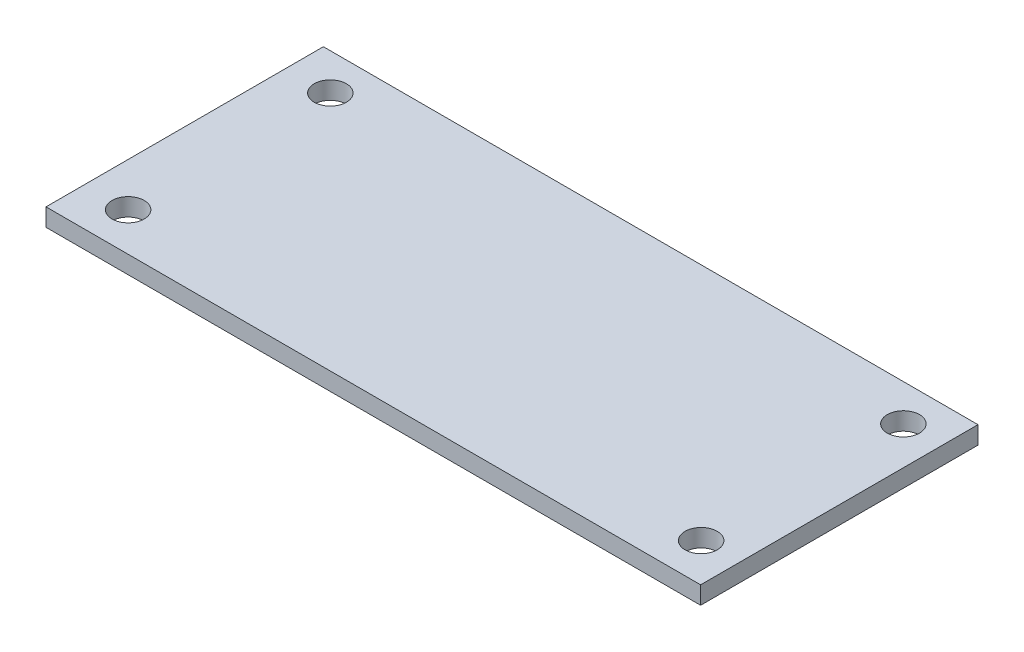
from build123d import *

# Parameters (mm, degrees)
SKETCH1_W                 = 59.944
SKETCH1_H                 = 25.4
BOSS_EXTRUDE1_DEPTH       = 1.6256
F_4_CLEARANCE_HOLE1_D     = 2.9464
F_4_CLEARANCE_HOLE1_DEPTH = 56.388
F_4_CLEARANCE_HOLE1_TIP   = 0.885187864


with BuildPart() as part:
    # Sketch1 → Boss-Extrude1 (new body)
    with BuildSketch(Plane(origin=(0, 0, 0), x_dir=(1, 0, 0), z_dir=(0, 1, 0))):
        Rectangle(SKETCH1_W, SKETCH1_H)
    extrude(amount=BOSS_EXTRUDE1_DEPTH)

    # #4 Clearance Hole1
    with Locations(Plane(origin=(0, 0, 0), x_dir=(-1, 0, 0), z_dir=(0, -1, 0))):
        with Locations((25.9842, -9.1694), (-26.4922, -9.1694), (-26.4922, 9.3472), (25.9842, 9.3472)):
            Hole(F_4_CLEARANCE_HOLE1_D / 2, depth=F_4_CLEARANCE_HOLE1_DEPTH)
            with Locations((0, 0, -(F_4_CLEARANCE_HOLE1_DEPTH + F_4_CLEARANCE_HOLE1_TIP / 2))):  # 118° drill point
                Cone(0, F_4_CLEARANCE_HOLE1_D / 2, F_4_CLEARANCE_HOLE1_TIP, mode=Mode.SUBTRACT)


solid = part.part
